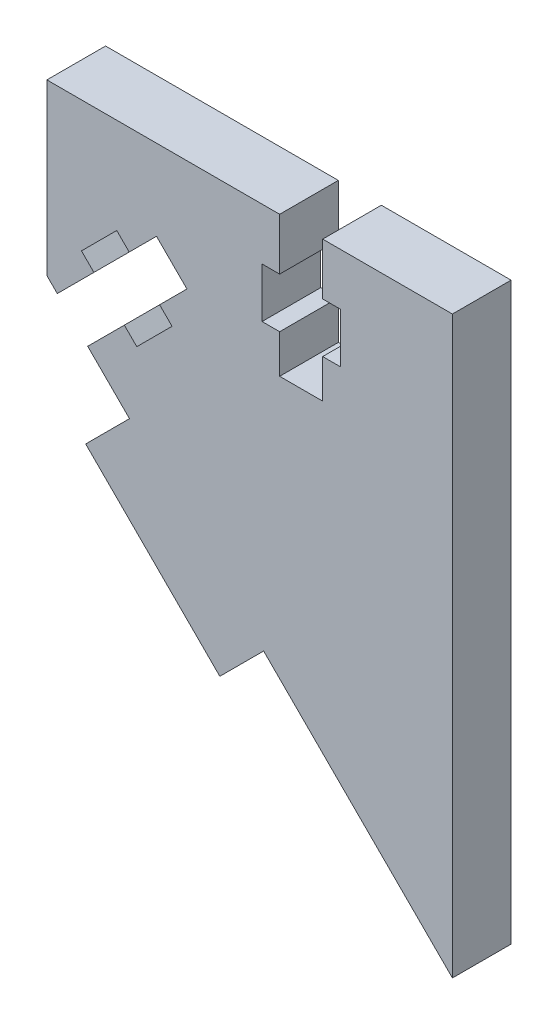
from build123d import *

# Parameters (mm, degrees)
RESSALTO_EXTRUS_O1_DEPTH = 6


with BuildPart() as part:
    # Model → Ressalto-extrusão1 (new body)
    with BuildSketch(Plane.XY):
        Polygon((38.562707977, 56.459489718), (41.355779414, 59.252561154), (44.467052306, 56.141288263), (41.673980869, 53.348216826), (42.946771723, 52.075425972), (39.340529008, 48.469183257), (38.067738154, 49.741974111), (34.320073347, 45.994309304), (38.593159239, 41.721223412), (34.112799553, 37.240863725), (47.830667067, 23.522996211), (52.311026753, 28.003355898), (71.615041807, 8.699340844), (71.615041807, 67.49933614), (58.348140448, 67.49933614), (58.348140448, 62.199337742), (60.148138536, 62.199337742), (60.148138536, 57.099340386), (58.348140448, 57.099340386), (58.348140448, 53.149340879), (53.948136128, 53.149340879), (53.948136128, 57.099340386), (52.148138041, 57.099340386), (52.148138041, 62.199337742), (53.948136128, 62.199337742), (53.948136128, 67.49933614), (30.148140368, 67.49933614), (30.148140368, 50.166242282), (31.208800455, 49.105582195), (34.956465263, 52.853247003), (33.683674409, 54.126037857), (37.289917123, 57.732280572), align=None)
    extrude(amount=RESSALTO_EXTRUS_O1_DEPTH)


solid = part.part
